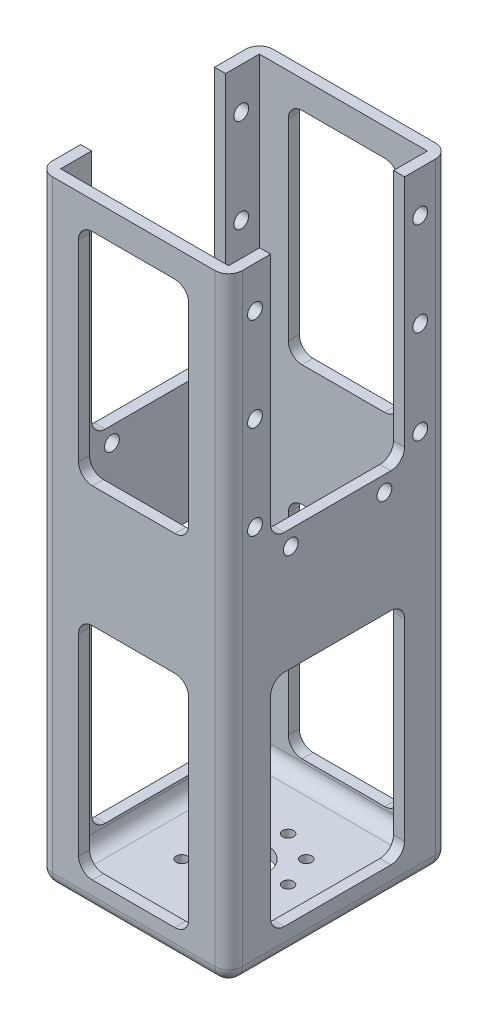
from build123d import *

# Parameters (mm, degrees)
SKETCH2_W           = 34.5
SKETCH2_H           = 40.1
BOSS_EXTRUDE1_DEPTH = 2
SKETCH1_R           = 1
SKETCH1_R_2         = 4.25
CUT_EXTRUDE2_DEPTH  = 3
SKETCH3_W           = 34.5
SKETCH3_H           = 40.1
SKETCH3_W_2         = 30.5
SKETCH3_H_2         = 36.1
BOSS_EXTRUDE3_DEPTH = 110
SKETCH4_W           = 24.336491673
SKETCH4_H           = 45
SKETCH4_H_2         = 40
CUT_EXTRUDE3_DEPTH  = 35.5
SKETCH5_W           = 20
SKETCH5_H           = 40
CUT_EXTRUDE4_DEPTH  = 41.1
FILLET1_R           = 2.5
SKETCH7_R           = 1.350000001
CUT_EXTRUDE5_DEPTH  = 35.5


with BuildPart() as part:
    # Sketch2 → Boss-Extrude1 (new body)
    with BuildSketch(Plane(origin=(0, 0, 0), x_dir=(1, 0, 0), z_dir=(0, 1, 0))):
        Rectangle(SKETCH2_W, SKETCH2_H)
    extrude(amount=BOSS_EXTRUDE1_DEPTH)

    # Sketch1 → Cut-Extrude2 (cut, through all)
    with BuildSketch(Plane(origin=(0, 0, 0), x_dir=(1, 0, 0), z_dir=(0, 1, 0))):
        with Locations((0, 8)):
            Circle(SKETCH1_R)
        with Locations((5.656854249, 5.656854249)):
            Circle(SKETCH1_R)
        with Locations((8, 0)):
            Circle(SKETCH1_R)
        with Locations((5.656854249, -5.656854249)):
            Circle(SKETCH1_R)
        with Locations((0, -8)):
            Circle(SKETCH1_R)
        with Locations((-5.656854249, -5.656854249)):
            Circle(SKETCH1_R)
        with Locations((-8, 0)):
            Circle(SKETCH1_R)
        with Locations((-5.656854249, 5.656854249)):
            Circle(SKETCH1_R)
        Circle(SKETCH1_R_2)
    extrude(amount=CUT_EXTRUDE2_DEPTH, mode=Mode.SUBTRACT)

    # Sketch3 → Boss-Extrude3 (add)
    with BuildSketch(Plane(origin=(0, 2, 0), x_dir=(1, 0, 0), z_dir=(0, 1, 0))):
        Rectangle(SKETCH3_W, SKETCH3_H)
        Rectangle(SKETCH3_W_2, SKETCH3_H_2, mode=Mode.SUBTRACT)
    extrude(amount=BOSS_EXTRUDE3_DEPTH)

    # Sketch4 → Cut-Extrude3 (cut, through all)
    with BuildSketch(Plane.ZY.offset(17.25)):
        with Locations((0.249999999, 89.5)):
            Rectangle(SKETCH4_W, SKETCH4_H)
        with Locations((0.249999999, 25)):
            Rectangle(SKETCH4_W, SKETCH4_H_2)
    extrude(amount=-CUT_EXTRUDE3_DEPTH, mode=Mode.SUBTRACT)

    # Sketch5 → Cut-Extrude4 (cut, through all)
    with BuildSketch(Plane.XY.offset(20.05)):
        with Locations((0, 25)):
            Rectangle(SKETCH5_W, SKETCH5_H)
        with Locations((0, 87)):
            Rectangle(SKETCH5_W, SKETCH5_H)
    extrude(amount=-CUT_EXTRUDE4_DEPTH, mode=Mode.SUBTRACT)

    # Fillet1
    fillet1_edges = [part.edges().sort_by_distance(p)[0] for p in [
        (16.25, 5, -11.918245837),
        (16.25, 45, -11.918245837),
        (16.25, 45, 12.418245836),
        (16.25, 5, 12.418245836),
        (-16.25, 5, -11.918245837),
        (-16.25, 45, -11.918245837),
        (-16.25, 45, 12.418245836),
        (-16.25, 5, 12.418245836),
        (10, 45, -19.05),
        (10, 5, -19.05),
        (-10, 5, -19.05),
        (-10, 45, -19.05),
        (10, 45, 19.05),
        (10, 5, 19.05),
        (-10, 5, 19.05),
        (-10, 45, 19.05),
        (10, 107, -19.05),
        (10, 67, -19.05),
        (-10, 67, -19.05),
        (-10, 107, -19.05),
        (10, 107, 19.05),
        (10, 67, 19.05),
        (-10, 67, 19.05),
        (-10, 107, 19.05),
        (0, 0, 20.05),
        (-17.25, 0, 0),
        (0, 0, -20.05),
        (15.25, 2, 0),
        (0, 2, -18.05),
        (-15.25, 2, 0),
        (0, 2, 18.05),
        (17.25, 0, 0),
        (17.25, 56, 20.05),
        (-17.25, 56, 20.05),
        (-17.25, 56, -20.05),
        (17.25, 56, -20.05),
        (16.25, 67, 12.418245836),
        (16.25, 67, -11.918245837),
        (-16.25, 67, 12.418245836),
        (-16.25, 67, -11.918245837),
    ]]
    fillet(fillet1_edges, radius=FILLET1_R)

    # Sketch7 → Cut-Extrude5 (cut, through all)
    with BuildSketch(Plane.ZY.offset(17.25)):
        with Locations((-14.75, 104.5)):
            Circle(SKETCH7_R)
        with Locations((-14.75, 87.5)):
            Circle(SKETCH7_R)
        with Locations((-14.75, 70.5)):
            Circle(SKETCH7_R)
        with Locations((15.25, 104.5)):
            Circle(SKETCH7_R)
        with Locations((15.25, 87.5)):
            Circle(SKETCH7_R)
        with Locations((15.25, 70.5)):
            Circle(SKETCH7_R)
        with Locations((-8.25, 64.2)):
            Circle(SKETCH7_R)
        with Locations((8.75, 64.2)):
            Circle(SKETCH7_R)
    extrude(amount=-CUT_EXTRUDE5_DEPTH, mode=Mode.SUBTRACT)


solid = part.part
